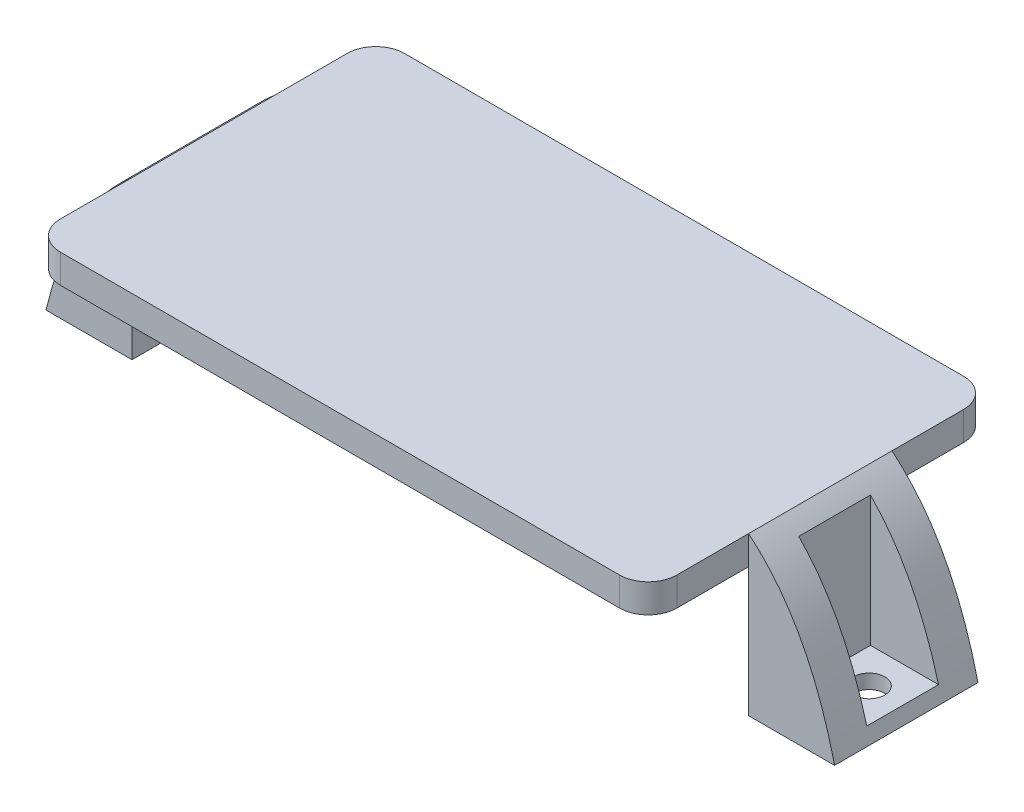
from build123d import *

# Parameters (mm, degrees)
SKETCH1_W           = 54.61
SKETCH1_H           = 30.48
BOSS_EXTRUDE1_DEPTH = 2.54
FILLET1_R           = 2.54
BOSS_EXTRUDE2_DEPTH = 6.35
SKETCH3_W           = 6.35
SKETCH3_H           = 6.35
CUT_EXTRUDE1_DEPTH  = 12.7
SKETCH4_R           = 1.397
CUT_EXTRUDE2_DEPTH  = 14.9700001


with BuildPart() as part:
    # Sketch1 → Boss-Extrude1 (new body)
    with BuildSketch(Plane(origin=(0, 0, 0), x_dir=(1, 0, 0), z_dir=(0, 1, 0))):
        Rectangle(SKETCH1_W, SKETCH1_H)
    extrude(amount=-BOSS_EXTRUDE1_DEPTH)

    # Fillet1
    fillet1_edges = [part.edges().sort_by_distance(p)[0] for p in [
        (27.305, -1.27, 15.24),
        (-27.305, -1.27, 15.24),
        (-27.305, -1.27, -15.24),
        (27.305, -1.27, -15.24),
    ]]
    fillet(fillet1_edges, radius=FILLET1_R)

    # Sketch2 → Boss-Extrude2 (add, symmetric)
    with BuildSketch(Plane.XY):
        with BuildLine():
            add(Edge.make_bspline(
                [(34.925, -13.97), (32.641767313, -4.413096047), (27.305, 0)],
                knots=[0, 0, 0, 0.368203859, 0.368203859, 0.368203859], degree=2))
            Line((27.305, 0), (27.305, -13.97))
            Line((27.305, -13.97), (34.925, -13.97))
        make_face()
    boss_extrude2 = extrude(amount=BOSS_EXTRUDE2_DEPTH, both=True)

    # Sketch3 → Cut-Extrude1 (cut)
    with BuildSketch(Plane(origin=(0, 0, 0), x_dir=(1, 0, 0), z_dir=(0, 1, 0))):
        with Locations((31.75, 0)):
            Rectangle(SKETCH3_W, SKETCH3_H)
    cut_extrude1 = extrude(amount=-CUT_EXTRUDE1_DEPTH, mode=Mode.SUBTRACT)

    # Sketch4 → Cut-Extrude2 (cut, through all)
    with BuildSketch(Plane(origin=(0, -13.97, 0), x_dir=(-1, 0, 0), z_dir=(0, -1, 0))):
        with Locations((-31.623, 0)):
            Circle(SKETCH4_R)
    cut_extrude2 = extrude(amount=-CUT_EXTRUDE2_DEPTH, mode=Mode.SUBTRACT)

    # Mirror1: Boss-Extrude2, Cut-Extrude1, Cut-Extrude2 across plane
    add(boss_extrude2.mirror(Plane(origin=(0, 0, 0), x_dir=(0, 0, 1), z_dir=(1, 0, 0))))
    add(cut_extrude1.mirror(Plane(origin=(0, 0, 0), x_dir=(0, 0, 1), z_dir=(1, 0, 0))), mode=Mode.SUBTRACT)
    add(cut_extrude2.mirror(Plane(origin=(0, 0, 0), x_dir=(0, 0, 1), z_dir=(1, 0, 0))), mode=Mode.SUBTRACT)


solid = part.part
